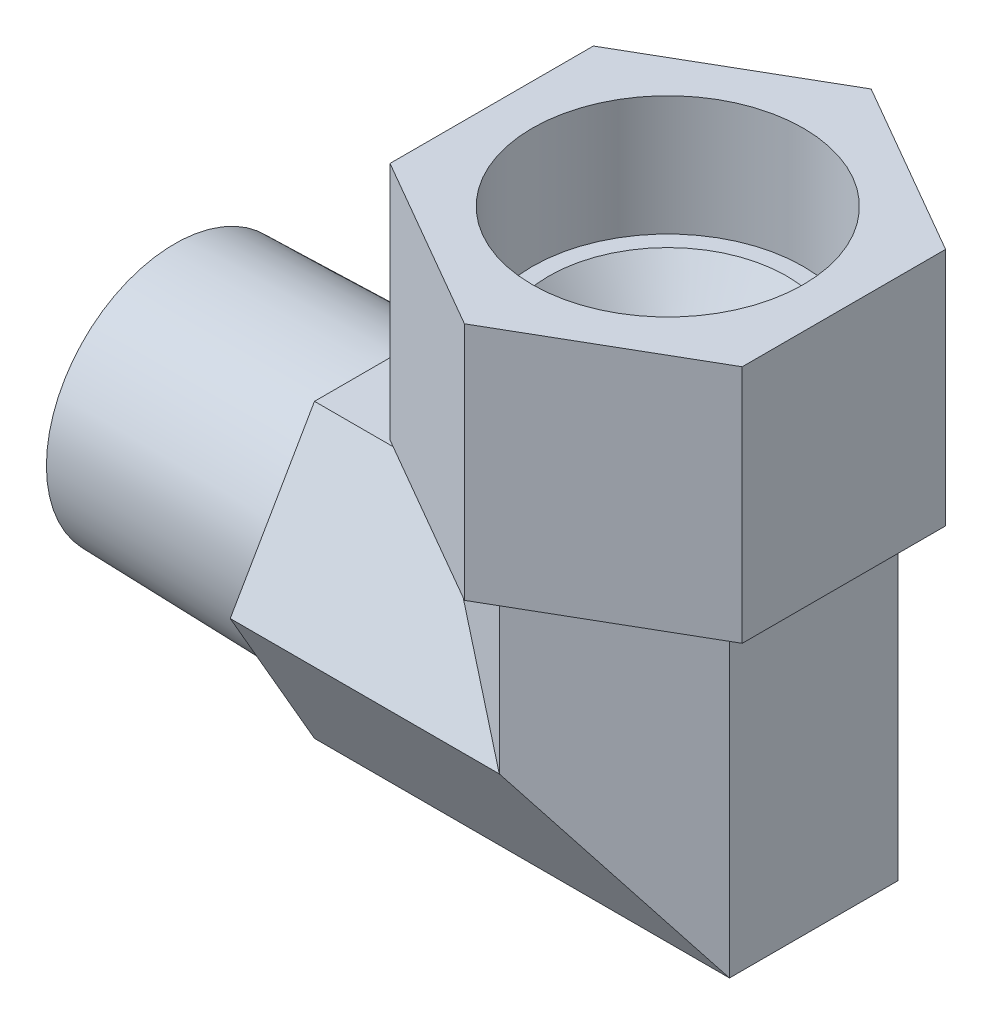
from build123d import *

# Parameters (mm, degrees)
SKETCH3_R           = 9.1313
CUT_EXTRUDE1_DEPTH  = 52.1843
SKETCH4_R           = 7.7343
CUT_EXTRUDE2_DEPTH  = 25.908
CHAMFER1_SIZE       = 3.9624
CHAMFER1_SIZE2      = 2.985882568
SKETCH5_R           = 11.56335
CUT_EXTRUDE3_DEPTH  = 20.19808
CUT_EXTRUDE3_TAPER  = 1.47
SKETCH6_R           = 12.081672541
CUT_EXTRUDE4_DEPTH  = 20.19808
SKETCH7_R           = 12.2174
BOSS_EXTRUDE1_DEPTH = 10.795


with BuildPart() as part:
    # Sweep1: sweep along a path in Sketch1
    with BuildLine(Plane.XY) as sweep1_path:
        Line((0, 0), (44.45, 0))
        Line((44.45, 0), (44.45, 25.908))
    # Sketch2 → Sweep1 (sweep)
    with BuildSketch(Plane(origin=(0, 0, 0), x_dir=(0, 0, -1), z_dir=(1, 0, 0))):
        Polygon((7.596312962, 13.1572), (-7.596312962, 13.1572), (-15.192625924, 0), (-7.596312962, -13.1572), (7.596312962, -13.1572), (15.192625924, 0), align=None)
    sweep(path=sweep1_path.line, transition=Transition.RIGHT)

    # Sketch3 → Cut-Extrude1 (cut)
    with BuildSketch(Plane.ZY):
        Circle(SKETCH3_R)
    extrude(amount=-CUT_EXTRUDE1_DEPTH, mode=Mode.SUBTRACT)

    # Sketch4 → Cut-Extrude2 (cut)
    with BuildSketch(Plane(origin=(0, 25.908, 0), x_dir=(1, 0, 0), z_dir=(0, 1, 0))):
        with Locations((44.45, 0)):
            Circle(SKETCH4_R)
    extrude(amount=-CUT_EXTRUDE2_DEPTH, mode=Mode.SUBTRACT)

    # Chamfer1
    chamfer1_edges = [part.edges().sort_by_distance(p)[0] for p in [
        (36.7157, 25.908, 0),
    ]]
    chamfer1_side = [part.faces().sort_by_distance(p)[0] for p in [
        (36.7157, 15.380996251, 0),
    ]]
    chamfer(chamfer1_edges, length=CHAMFER1_SIZE, length2=CHAMFER1_SIZE2, reference=chamfer1_side[0])

    # Sketch5 → Cut-Extrude3 (cut)
    with BuildSketch(Plane.ZY):
        Polygon((-7.596312962, 13.1572), (-15.192625924, 0), (-7.596312962, -13.1572), (7.596312962, -13.1572), (15.192625924, 0), (7.596312962, 13.1572), align=None)
        Circle(SKETCH5_R, mode=Mode.SUBTRACT)
    extrude(amount=-CUT_EXTRUDE3_DEPTH, taper=CUT_EXTRUDE3_TAPER, mode=Mode.SUBTRACT)

    # Sketch6 → Cut-Extrude4 (cut)
    with BuildSketch(Plane.ZY):
        Polygon((-15.192625924, 0), (-7.596312962, 13.1572), (7.596312962, 13.1572), (15.192625924, 0), (7.596312962, -13.1572), (-7.596312962, -13.1572), align=None)
        Circle(SKETCH6_R, mode=Mode.SUBTRACT)
    extrude(amount=-CUT_EXTRUDE4_DEPTH, mode=Mode.SUBTRACT)

    # Sketch7 → Boss-Extrude1 (add, symmetric)
    with BuildSketch(Plane(origin=(0, 25.908, 0), x_dir=(1, 0, 0), z_dir=(0, 1, 0))):
        Polygon((44.45, 18.330871047), (28.575, 9.165435523), (28.575, -9.165435523), (44.45, -18.330871047), (60.325, -9.165435523), (60.325, 9.165435523), align=None)
        with Locations((44.45, 0)):
            Circle(SKETCH7_R, mode=Mode.SUBTRACT)
    extrude(amount=BOSS_EXTRUDE1_DEPTH, both=True)


solid = part.part
